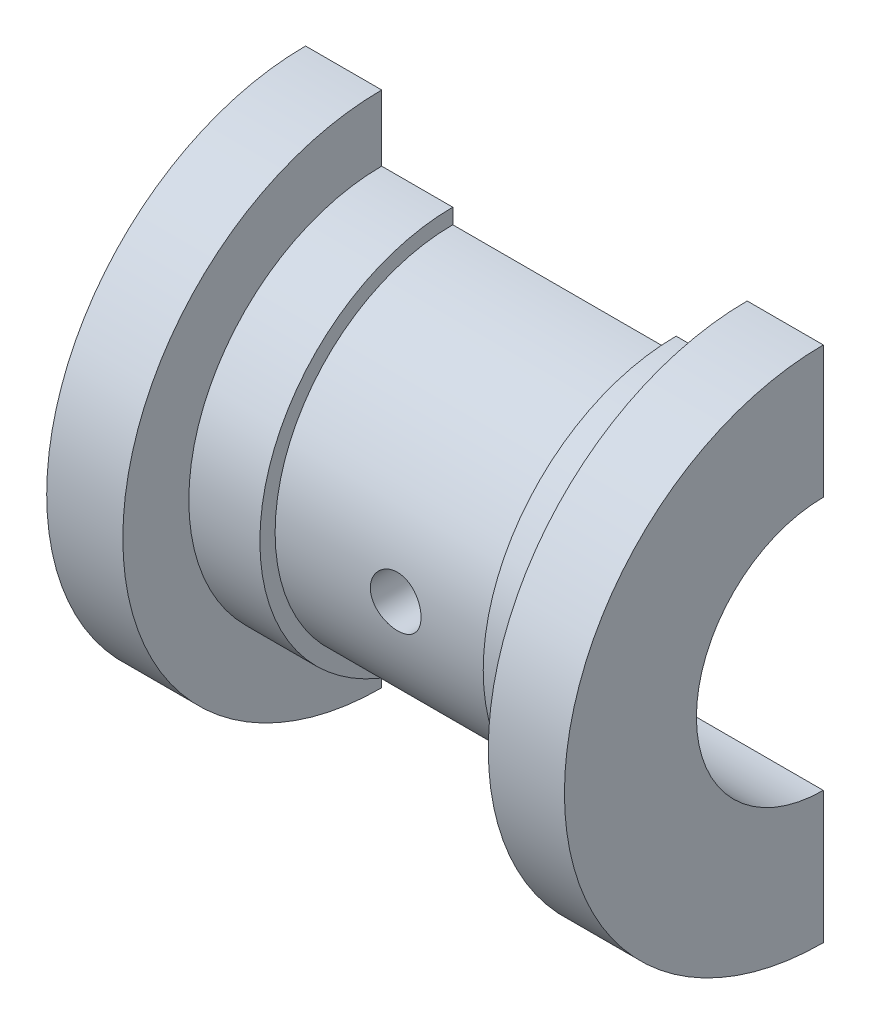
from build123d import *

# Parameters (mm, degrees)
REVOLVE1_ANGLE            = 180
CUT_EXTRUDE1_DEPTH        = 52
F_5_0MM_DOWEL_HOLE1_D     = 5
F_5_0MM_DOWEL_HOLE1_DEPTH = 21.19
F_5_0MM_DOWEL_HOLE1_TIP   = 1.502151548


with BuildPart() as part:
    # Sketch1 → Revolve1 (revolve)
    with BuildSketch(Plane.XY):
        Polygon((0, 0), (0, 25.5), (7.5, 25.5), (7.5, 19), (14.5, 19), (14.5, 17.5), (36.5, 17.5), (36.5, 19), (43.5, 19), (43.5, 25.5), (51, 25.5), (51, 0), align=None)
    revolve(axis=Axis((0, 0, 0), (1, 0, 0)), revolution_arc=REVOLVE1_ANGLE)

    # Sketch2 → Cut-Extrude1 (cut, through all)
    with BuildSketch(Plane.ZY):
        with BuildLine():
            Line((0, -12.5), (0, 12.5))
            ThreePointArc((0, 12.5), (12.5, 0), (0, -12.5))
        make_face()
    extrude(amount=-CUT_EXTRUDE1_DEPTH, mode=Mode.SUBTRACT)

    # Ø5.0mm Dowel Hole1
    with Locations(Plane(origin=(26.375948841, -0.029198295, 12.499965898), x_dir=(0, -0.999997272, -0.002335864), z_dir=(0, 0.002335864, -0.999997272))):
        with Locations((0, 0)):
            Hole(F_5_0MM_DOWEL_HOLE1_D / 2, depth=F_5_0MM_DOWEL_HOLE1_DEPTH)
            with Locations((0, 0, -(F_5_0MM_DOWEL_HOLE1_DEPTH + F_5_0MM_DOWEL_HOLE1_TIP / 2))):  # 118° drill point
                Cone(0, F_5_0MM_DOWEL_HOLE1_D / 2, F_5_0MM_DOWEL_HOLE1_TIP, mode=Mode.SUBTRACT)


solid = part.part
